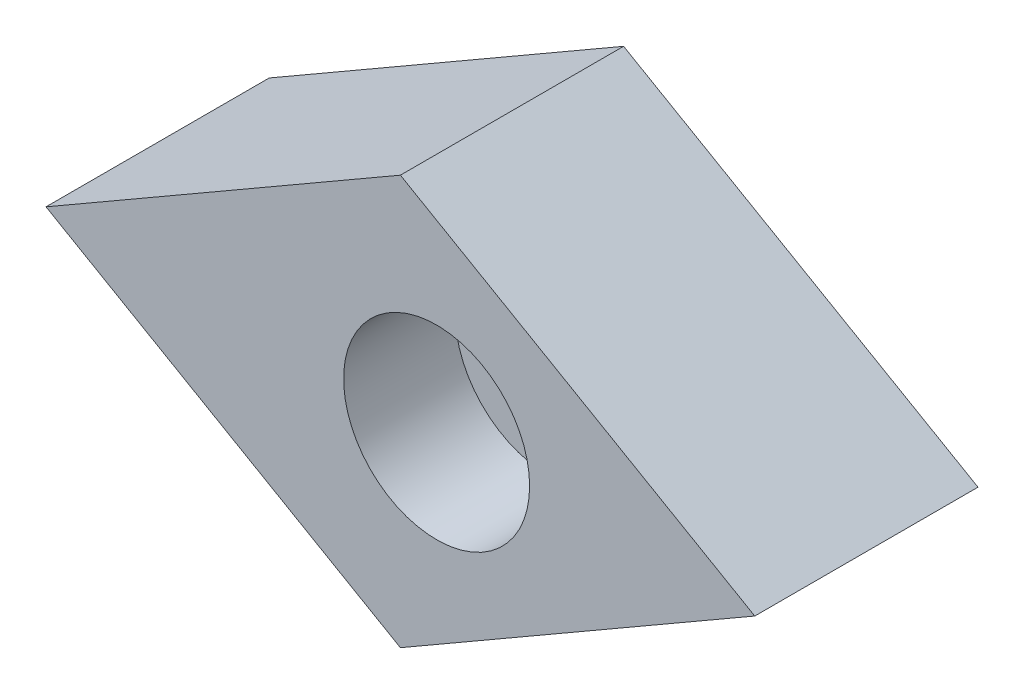
from build123d import *

# Parameters (mm, degrees)
EXTRUDE_1_DEPTH           = 6
HOLE_WIZARD_1_D           = 3
HOLE_WIZARD_1_DEPTH       = 6
HOLE_WIZARD_1_CBORE_D     = 5
HOLE_WIZARD_1_CBORE_DEPTH = 3


with BuildPart() as part:
    # 草图1 → 凸台-拉伸1 (new body)
    with BuildSketch(Plane.XY):
        Polygon((0, 5.5), (-9.526279442, 0), (0, -5.5), (9.526279442, 0), align=None)
    extrude(amount=EXTRUDE_1_DEPTH)

    # 孔1
    with Locations(Plane(origin=(0.973720558, 0, 6), x_dir=(1, 0, 0), z_dir=(0, 0, 1))):
        with Locations((0, 0)):
            CounterBoreHole(HOLE_WIZARD_1_D / 2, HOLE_WIZARD_1_CBORE_D / 2, HOLE_WIZARD_1_CBORE_DEPTH, depth=HOLE_WIZARD_1_DEPTH)


solid = part.part
